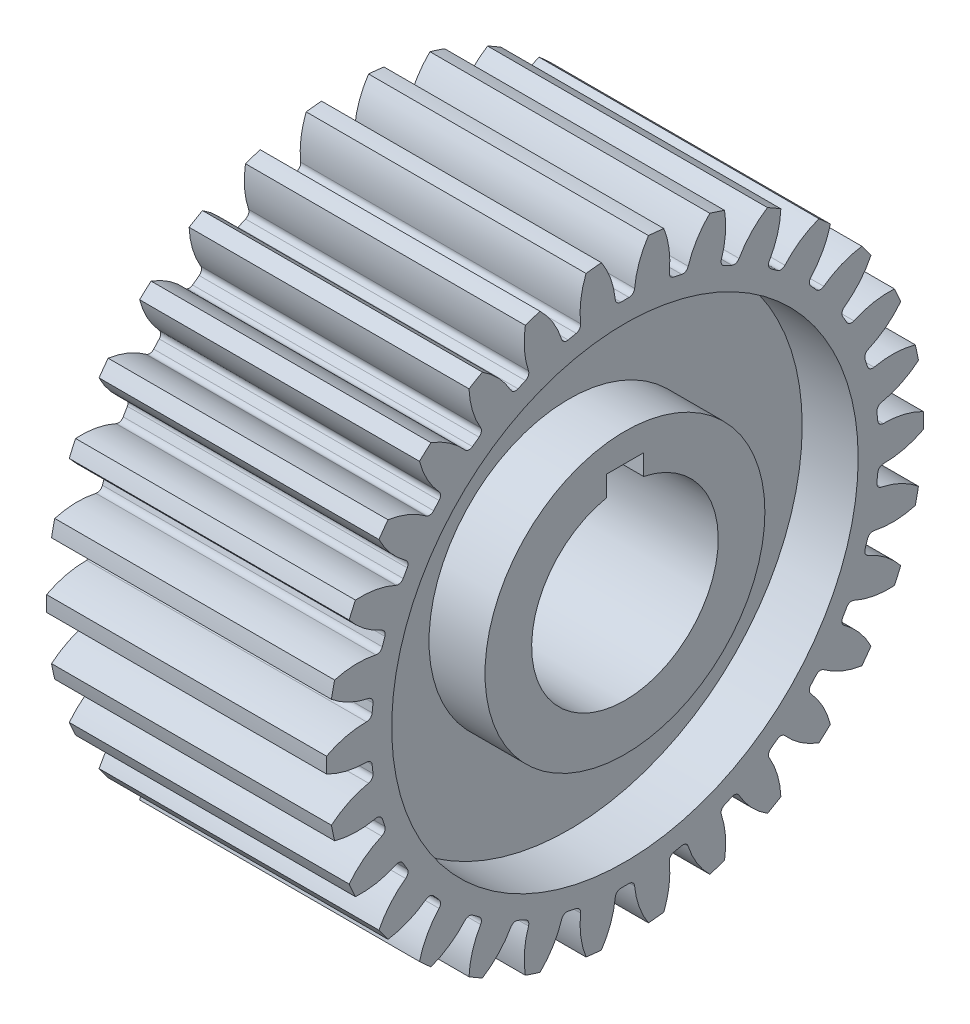
from build123d import *

# Parameters (mm, degrees)
SKETCH1_R           = 16
BOSS_EXTRUDE1_DEPTH = 7.5
CUT_EXTRUDE1_DEPTH  = 16
SKETCH3_R           = 12.5
SKETCH3_R_2         = 7.5
CUT_EXTRUDE2_DEPTH  = 3
CUT_EXTRUDE3_DEPTH  = 16
CIRPATTERN1_COUNT   = 30


with BuildPart() as part:
    # Sketch1 → Boss-Extrude1 (new body, symmetric)
    with BuildSketch(Plane(origin=(0, 0, 0), x_dir=(0, 0, -1), z_dir=(1, 0, 0))):
        Circle(SKETCH1_R)
    extrude(amount=BOSS_EXTRUDE1_DEPTH, both=True)

    # Sketch2 → Cut-Extrude1 (cut, through all)
    with BuildSketch(Plane(origin=(7.5, 0, 0), x_dir=(0, 0, -1), z_dir=(1, 0, 0))):
        with BuildLine():
            Line((-1, 6), (1, 6))
            Line((1, 6), (1, 4.898979486))
            ThreePointArc((1, 4.898979486), (0, -5), (-1, 4.898979486))
            Line((-1, 4.898979486), (-1, 6))
        make_face()
    extrude(amount=-CUT_EXTRUDE1_DEPTH, mode=Mode.SUBTRACT)

    # Sketch3 → Cut-Extrude2 (cut)
    with BuildSketch(Plane(origin=(7.5, 0, 0), x_dir=(0, 0, -1), z_dir=(1, 0, 0))):
        Circle(SKETCH3_R)
        Circle(SKETCH3_R_2, mode=Mode.SUBTRACT)
    cut_extrude2 = extrude(amount=-CUT_EXTRUDE2_DEPTH, mode=Mode.SUBTRACT)

    # Mirror1: Cut-Extrude2 across plane
    add(cut_extrude2.mirror(Plane(origin=(0, 0, 0), x_dir=(0, 0, 1), z_dir=(1, 0, 0))), mode=Mode.SUBTRACT)

    # Sketch4 → Cut-Extrude3 (cut, through all)
    with BuildSketch(Plane(origin=(7.5, 0, 0), x_dir=(0, 0, -1), z_dir=(1, 0, 0))):
        with BuildLine():
            Line((-0.219874756, 13.6), (0.219874756, 13.6))
            ThreePointArc((0.219874756, 13.6), (0.421386888, 13.677754953), (0.518441911, 13.870714262))
            ThreePointArc((0.518441911, 13.870714262), (1.009154991, 15.525876188), (2.08, 16.88))
            ThreePointArc((2.08, 16.88), (0, 17.000581665), (-2.08, 16.88))
            ThreePointArc((-2.08, 16.88), (-1.009154991, 15.525876188), (-0.518441911, 13.870714262))
            ThreePointArc((-0.518441911, 13.870714262), (-0.421386888, 13.677754953), (-0.219874756, 13.6))
        make_face()
    cut_extrude3 = extrude(amount=-CUT_EXTRUDE3_DEPTH, mode=Mode.SUBTRACT)

    # CirPattern1: Cut-Extrude3 ×30 about axis
    cirpattern1_axis = Axis((0, 0, 0), (1, 0, 0))
    for i in range(1, CIRPATTERN1_COUNT):
        add(cut_extrude3.rotate(cirpattern1_axis, i * 360 / CIRPATTERN1_COUNT), mode=Mode.SUBTRACT)


solid = part.part
